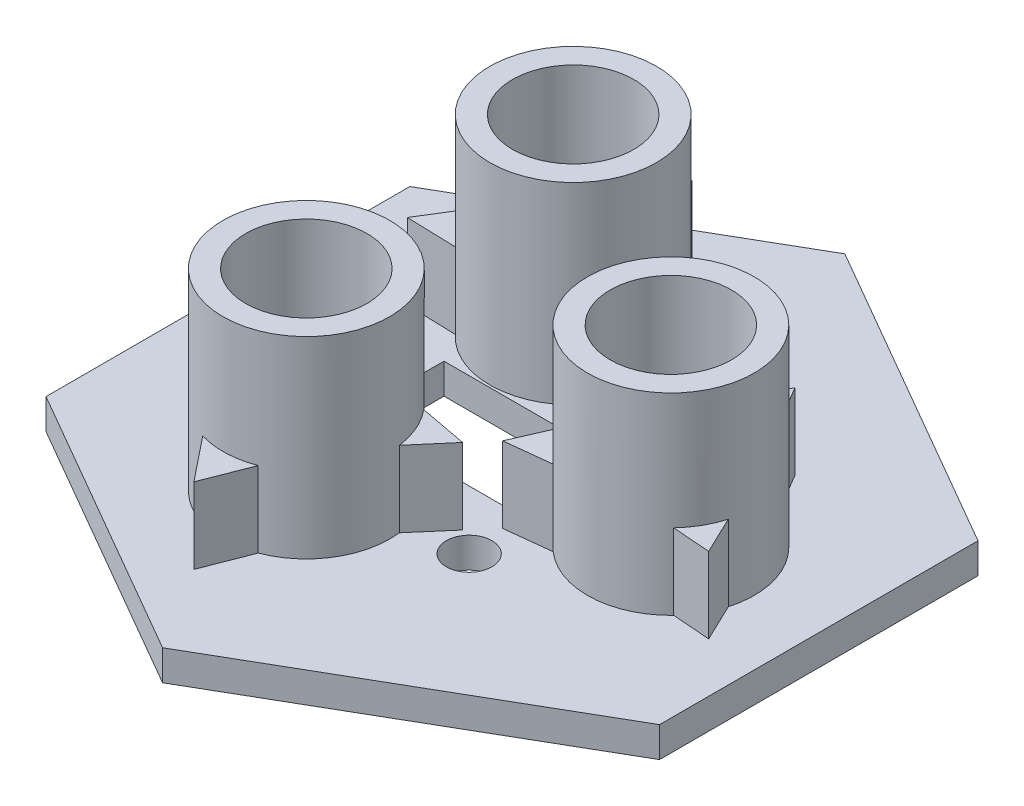
from build123d import *

# Parameters (mm, degrees)
BOSS_EXTRUDE1_DEPTH = 4
SKETCH2_R           = 11
BOSS_EXTRUDE2_DEPTH = 25.4
SKETCH3_R           = 8
CUT_EXTRUDE1_DEPTH  = 22.86
CUT_EXTRUDE2_DEPTH  = 22.86
SKETCH5_R           = 3
SKETCH5_W           = 22.8
SKETCH5_H           = 12.6
CUT_EXTRUDE3_DEPTH  = 4
BOSS_EXTRUDE3_DEPTH = 10
SKETCH7_W           = 4.84
SKETCH7_H           = 6.056432248
CUT_EXTRUDE4_DEPTH  = 10


with BuildPart() as part:
    # Sketch1 → Boss-Extrude1 (new body)
    with BuildSketch(Plane(origin=(0, 0, 0), x_dir=(1, 0, 0), z_dir=(0, 1, 0))):
        Polygon((76.2, 0), (-38.1, 65.991135768), (-38.1, -65.991135768), align=None)
    extrude(amount=BOSS_EXTRUDE1_DEPTH)

    # Sketch2 → Boss-Extrude2 (add)
    with BuildSketch(Plane(origin=(0, 4, 0), x_dir=(1, 0, 0), z_dir=(0, 1, 0))):
        with Locations((20.32, 0)):
            Circle(SKETCH2_R)
        with Locations((-10.16, 17.597636205)):
            Circle(SKETCH2_R)
        with Locations((-10.16, -17.597636205)):
            Circle(SKETCH2_R)
    extrude(amount=BOSS_EXTRUDE2_DEPTH)

    # Sketch3 → Cut-Extrude1 (cut)
    with BuildSketch(Plane(origin=(0, 29.4, 0), x_dir=(1, 0, 0), z_dir=(0, 1, 0))):
        with Locations((-10.16, 17.597636205)):
            Circle(SKETCH3_R)
        with Locations((20.32, 0)):
            Circle(SKETCH3_R)
        with Locations((-10.16, -17.597636205)):
            Circle(SKETCH3_R)
    extrude(amount=-CUT_EXTRUDE1_DEPTH, mode=Mode.SUBTRACT)

    # Sketch4 → Cut-Extrude2 (cut)
    with BuildSketch(Plane(origin=(0, 4, 0), x_dir=(1, 0, 0), z_dir=(0, 1, 0))):
        Polygon((-38.1, 65.991135768), (-1.726933041, 44.991135768), (-38.1, 23.991135768), align=None)
        Polygon((-38.1, -65.991135768), (-1.726933041, -44.991135768), (-38.1, -23.991135768), align=None)
        Polygon((76.2, 0), (39.826933041, -21), (39.826933041, 21), align=None)
    extrude(amount=-CUT_EXTRUDE2_DEPTH, mode=Mode.SUBTRACT)

    # Sketch5 → Cut-Extrude3 (cut)
    with BuildSketch(Plane(origin=(0, 0, 0), x_dir=(-1, 0, 0), z_dir=(0, -1, 0))):
        with Locations((-7.753054986, -14.0369452)):
            Circle(SKETCH5_R)
        with Locations((4.5, 0)):
            Rectangle(SKETCH5_W, SKETCH5_H)
    extrude(amount=-CUT_EXTRUDE3_DEPTH, mode=Mode.SUBTRACT)

    # Sketch6 → Boss-Extrude3 (add)
    with BuildSketch(Plane(origin=(0, 4, 0), x_dir=(1, 0, 0), z_dir=(0, 1, 0))):
        Polygon((-6.061319385, 26.273055398), (-10.196194275, 33.309488143), (-14.22248634, 26.210365074), align=None)
        Polygon((-15.553445676, 10.019414489), (-19.902730969, 18.097665314), (-24.724058755, 10.291948349), align=None)
        Polygon((4.666083615, 11.839822271), (-0.028890737, 18.987902238), (-3.871822401, 11.347895195), align=None)
        Polygon((25.015642032, 8.329035834), (20.285301804, 16.40202737), (15.659056164, 8.268936796), align=None)
        Polygon((33.276250833, -7.973152462), (30.121872493, -1.379377193), (25.988684773, -7.408036604), align=None)
        Polygon((15.659056164, -7.973152462), (10.527139401, -1.011359201), (7.064007962, -8.936626119), align=None)
        Polygon((-15.553445676, -9.963714295), (-23.645110056, -9.611162466), (-19.904596706, -16.795025293), align=None)
        Polygon((-5.170207238, -25.158366131), (-14.52400497, -26.588552978), (-8.608527963, -33.974086013), align=None)
        Polygon((-0.901197828, -18.18923766), (4.614077612, -11.758341231), (-3.712879784, -10.197420805), align=None)
    extrude(amount=BOSS_EXTRUDE3_DEPTH)

    # Sketch7 → Cut-Extrude4 (cut)
    with BuildSketch(Plane(origin=(0, 4, 0), x_dir=(1, 0, 0), z_dir=(0, 1, 0))):
        with Locations((6.9, 0)):
            Rectangle(SKETCH7_W, SKETCH7_H)
    extrude(amount=-CUT_EXTRUDE4_DEPTH, mode=Mode.SUBTRACT)


solid = part.part
